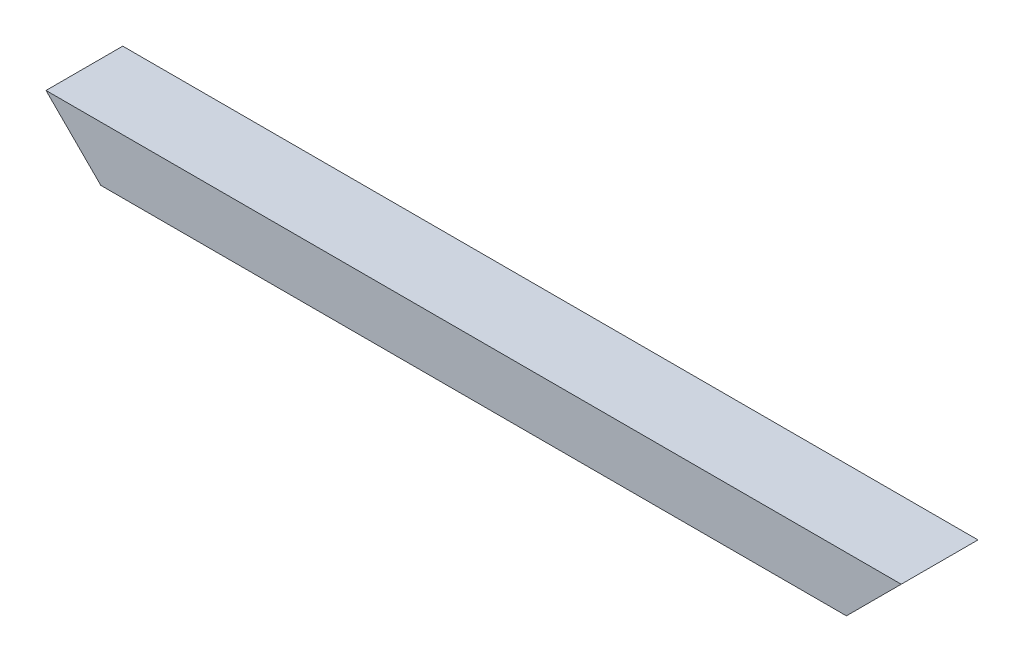
from build123d import *

# Parameters (mm, degrees)
BOSS_EXTRUDE1_DEPTH = 88.9


with BuildPart() as part:
    # Sketch2 → Boss-Extrude1 (new body)
    with BuildSketch(Plane.XY):
        Polygon((0, 0), (863.6, 0), (927.1, 63.5), (-63.5, 63.5), align=None)
    extrude(amount=BOSS_EXTRUDE1_DEPTH)


solid = part.part
